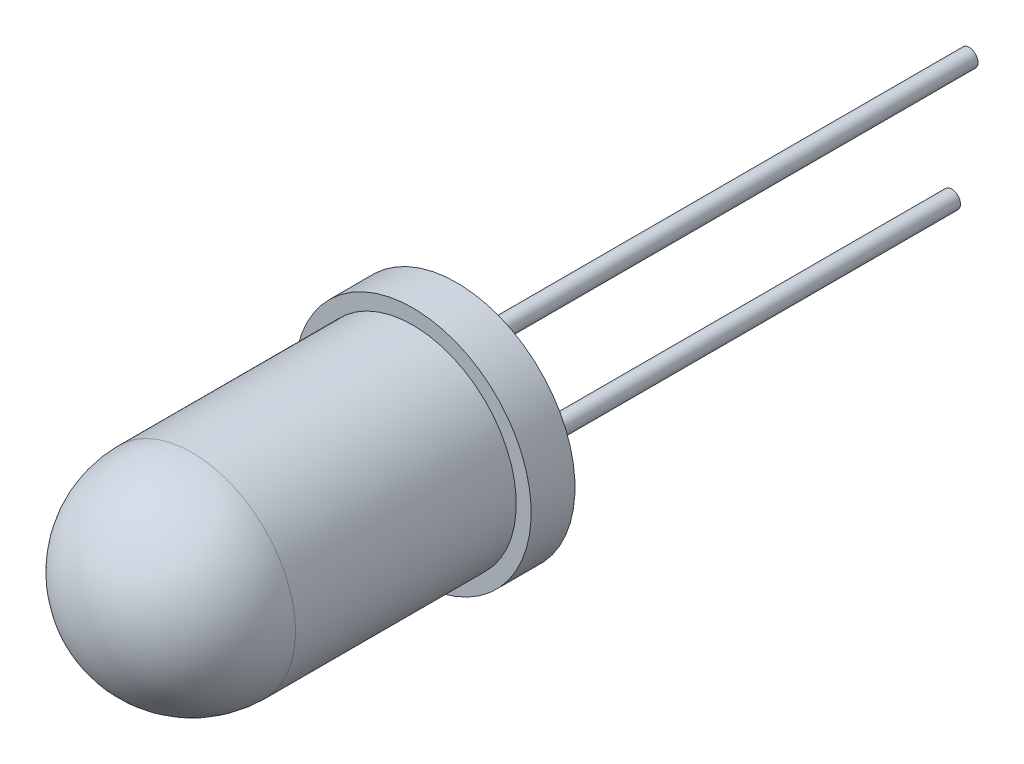
from build123d import *

# Parameters (mm, degrees)
SKETCH_3_R      = 0.2
EXTRUDE_1_DEPTH = 10
SKETCH_4_R      = 0.2
EXTRUDE_2_DEPTH = 3


with BuildPart() as part:
    # 草图2 → 旋转1 (revolve)
    with BuildSketch(Plane(origin=(0, 0, 0), x_dir=(1, 0, 0), z_dir=(0, 1, 0))):
        with BuildLine():
            Line((2.36, -6.04), (2.36, -1))
            Line((2.36, -1), (2.7, -1))
            Line((2.7, -1), (2.7, 0))
            Line((2.7, 0), (0, 0))
            Line((0, 0), (0, -8.4))
            ThreePointArc((0, -8.4), (1.668772004, -7.708772004), (2.36, -6.04))
        make_face()
    revolve(axis=Axis((0, 0, 0), (0, 0, 1)))

    # 草图3 → 凸台-拉伸1 (add)
    with BuildSketch(Plane(origin=(0, 0, 0), x_dir=(-1, 0, 0), z_dir=(0, 0, -1))):
        with Locations((1.3, 0)):
            Circle(SKETCH_3_R)
        with Locations((-1.3, 0)):
            Circle(SKETCH_3_R)
    extrude(amount=EXTRUDE_1_DEPTH)

    # 草图4 → 凸台-拉伸2 (add)
    with BuildSketch(Plane(origin=(0, 0, -10), x_dir=(-1, 0, 0), z_dir=(0, 0, -1))):
        with Locations((1.3, 0)):
            Circle(SKETCH_4_R)
    extrude(amount=EXTRUDE_2_DEPTH)


solid = part.part
